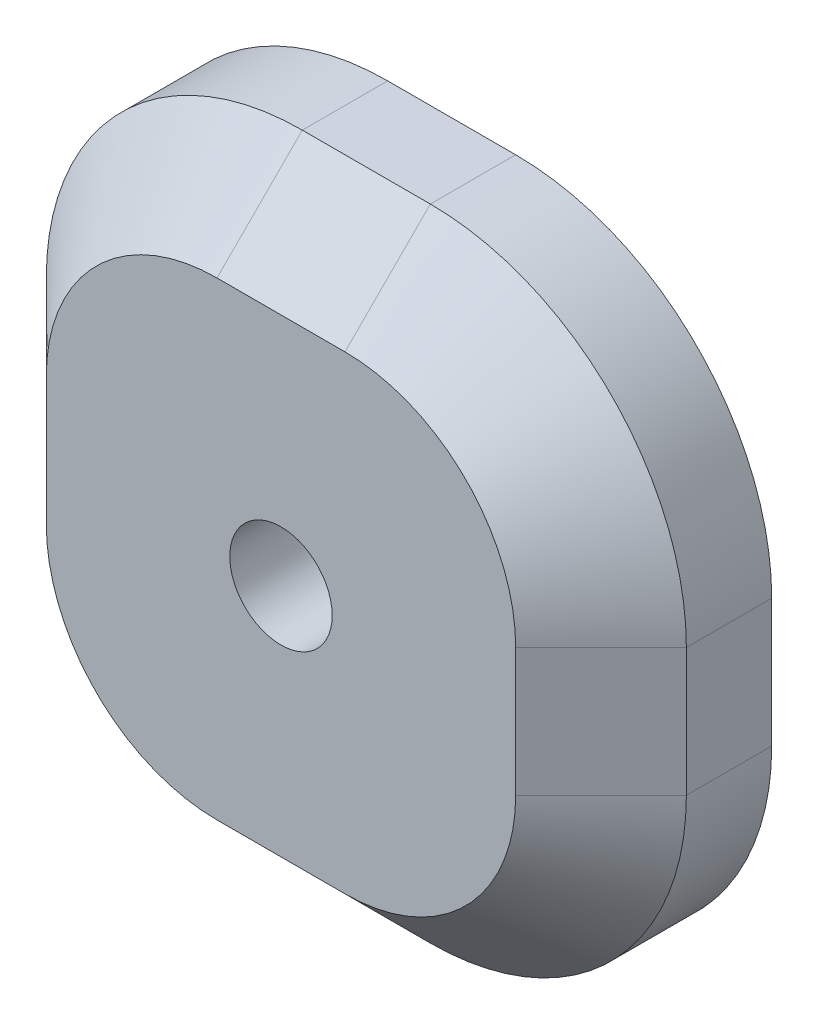
from build123d import *

# Parameters (mm, degrees)
SALIENTE_EXTRUIR3_DEPTH = 20
CHAFL_N1_SIZE           = 10
TALADRO2_D              = 12
TALADRO2_DEPTH          = 10
TALADRO2_TIP            = 3.605163714
TALADRO3_D              = 12
TALADRO3_DEPTH          = 10
TALADRO3_TIP            = 3.605163714


with BuildPart() as part:
    # Croquis1 → Saliente-Extruir3 (new body)
    with BuildSketch(Plane.XY):
        with BuildLine():
            Line((-7.5, 37.5), (7.5, 37.5))
            ThreePointArc((7.5, 37.5), (28.713203436, 28.713203436), (37.5, 7.5))
            Line((37.5, 7.5), (37.5, -7.5))
            ThreePointArc((37.5, -7.5), (28.713203436, -28.713203436), (7.5, -37.5))
            Line((7.5, -37.5), (-7.5, -37.5))
            ThreePointArc((-7.5, -37.5), (-28.713203436, -28.713203436), (-37.5, -7.5))
            Line((-37.5, -7.5), (-37.5, 7.5))
            ThreePointArc((-37.5, 7.5), (-28.713203436, 28.713203436), (-7.5, 37.5))
        make_face()
    extrude(amount=SALIENTE_EXTRUIR3_DEPTH)

    # Chaflán1
    chafl_n1_edges = [part.edges().sort_by_distance(p)[0] for p in [
        (28.713203436, -28.713203436, 20),
        (37.5, 0, 20),
        (28.713203436, 28.713203436, 20),
        (0, 37.5, 20),
        (-28.713203436, 28.713203436, 20),
        (-37.5, 0, 20),
        (-28.713203436, -28.713203436, 20),
        (0, -37.5, 20),
    ]]
    chamfer(chafl_n1_edges, length=CHAFL_N1_SIZE)

    # Taladro2
    with Locations(Plane(origin=(0, 0, 0), x_dir=(-1, 0, 0), z_dir=(0, 0, -1))):
        with Locations((-12.5, 12.5), (-12.5, -12.5), (12.5, -12.5), (12.5, 12.5)):
            Hole(TALADRO2_D / 2, depth=TALADRO2_DEPTH)
            with Locations((0, 0, -(TALADRO2_DEPTH + TALADRO2_TIP / 2))):  # 118° drill point
                Cone(0, TALADRO2_D / 2, TALADRO2_TIP, mode=Mode.SUBTRACT)

    # Taladro3
    with Locations(Plane.XY.offset(20)):
        with Locations((0, 0)):
            Hole(TALADRO3_D / 2, depth=TALADRO3_DEPTH)
            with Locations((0, 0, -(TALADRO3_DEPTH + TALADRO3_TIP / 2))):  # 118° drill point
                Cone(0, TALADRO3_D / 2, TALADRO3_TIP, mode=Mode.SUBTRACT)


solid = part.part
